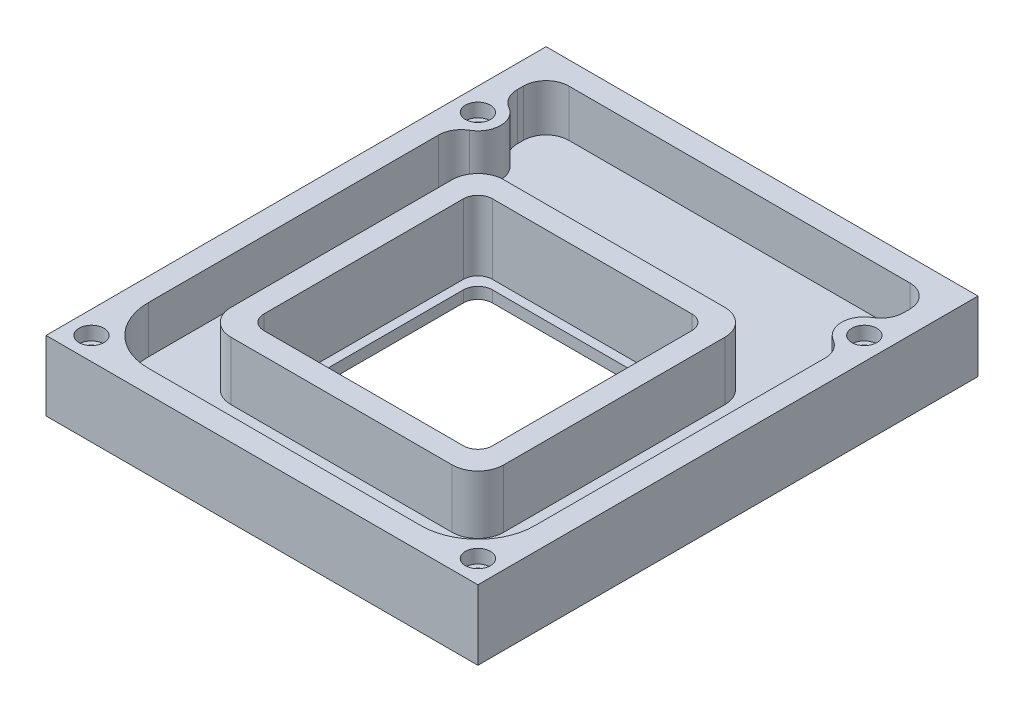
from build123d import *

# Parameters (mm, degrees)
SKETCH1_W           = 190
SKETCH1_H           = 220
SKETCH1_W_2         = 150
SKETCH1_H_2         = 180
SKETCH1_W_3         = 120
SKETCH1_H_3         = 120
SKETCH1_W_4         = 100
SKETCH1_H_4         = 100
BOSS_EXTRUDE1_DEPTH = 10
SKETCH1_3_W         = 190
SKETCH1_3_H         = 220
SKETCH1_3_W_2       = 150
SKETCH1_3_H_2       = 180
SKETCH1_3_W_3       = 120
SKETCH1_3_H_3       = 120
SKETCH1_3_W_4       = 100
SKETCH1_3_H_4       = 100
BOSS_EXTRUDE2_DEPTH = 35.693
SKETCH3_W           = 190
SKETCH3_H           = 220
SKETCH3_W_2         = 150
SKETCH3_H_2         = 180
CUT_EXTRUDE1_DEPTH  = 5
SKETCH5_R           = 5.5565
CUT_EXTRUDE2_DEPTH  = 22
SKETCH7_R           = 3.3
CUT_EXTRUDE3_DEPTH  = 14.693
CUT_EXTRUDE4_START  = -1e-06
SKETCH8_W           = 146
SKETCH8_H           = 180
CUT_EXTRUDE4_DEPTH  = 20.693001
FILLET1_R           = 10
SKETCH10_R          = 5.5
CUT_EXTRUDE5_DEPTH  = 6
BOSS_EXTRUDE5_START = -1e-06
BOSS_EXTRUDE5_DEPTH = 20.693001
CUT_EXTRUDE10_REACH = 37.693
SKETCH13_W          = 100.5
SKETCH13_H          = 100.5
FILLET2_R           = 11.35
SKETCH14_W          = 100.5
SKETCH14_H          = 100.5
SKETCH14_W_2        = 92.5
SKETCH14_H_2        = 92.5
BOSS_EXTRUDE6_DEPTH = 5
FILLET3_R           = 6.35
FILLET4_R           = 6.35


with BuildPart() as part:
    # Sketch1 → Boss-Extrude1 (new body)
    with BuildSketch(Plane(origin=(0, 0, 0), x_dir=(1, 0, 0), z_dir=(0, 1, 0))):
        with Locations((0, 15)):
            Rectangle(SKETCH1_W, SKETCH1_H)
        with Locations((0, 15)):
            Rectangle(SKETCH1_W_2, SKETCH1_H_2, mode=Mode.SUBTRACT)
        with Locations((0, 15)):
            Rectangle(SKETCH1_W_2, SKETCH1_H_2)
        Rectangle(SKETCH1_W_3, SKETCH1_H_3, mode=Mode.SUBTRACT)
        Rectangle(SKETCH1_W_3, SKETCH1_H_3)
        Rectangle(SKETCH1_W_4, SKETCH1_H_4, mode=Mode.SUBTRACT)
    extrude(amount=BOSS_EXTRUDE1_DEPTH)

    # Sketch1_3 → Boss-Extrude2 (add)
    with BuildSketch(Plane(origin=(0, 0, 0), x_dir=(1, 0, 0), z_dir=(0, 1, 0))):
        with Locations((0, 15)):
            Rectangle(SKETCH1_3_W, SKETCH1_3_H)
        with Locations((0, 15)):
            Rectangle(SKETCH1_3_W_2, SKETCH1_3_H_2, mode=Mode.SUBTRACT)
        Rectangle(SKETCH1_3_W_3, SKETCH1_3_H_3)
        Rectangle(SKETCH1_3_W_4, SKETCH1_3_H_4, mode=Mode.SUBTRACT)
    extrude(amount=BOSS_EXTRUDE2_DEPTH)

    # Sketch3 → Cut-Extrude1 (cut)
    with BuildSketch(Plane(origin=(0, 35.693, 0), x_dir=(1, 0, 0), z_dir=(0, 1, 0))):
        with Locations((0, 15)):
            Rectangle(SKETCH3_W, SKETCH3_H)
        with Locations((0, 15)):
            Rectangle(SKETCH3_W_2, SKETCH3_H_2, mode=Mode.SUBTRACT)
    extrude(amount=-CUT_EXTRUDE1_DEPTH, mode=Mode.SUBTRACT)

    # Sketch5 → Cut-Extrude2 (cut)
    with BuildSketch(Plane(origin=(0, 0, 0), x_dir=(-1, 0, 0), z_dir=(0, -1, 0))):
        with Locations((85, 85)):
            Circle(SKETCH5_R)
        with Locations((85, -85)):
            Circle(SKETCH5_R)
        with Locations((-85, -85)):
            Circle(SKETCH5_R)
        with Locations((-85, 85)):
            Circle(SKETCH5_R)
    extrude(amount=-CUT_EXTRUDE2_DEPTH, mode=Mode.SUBTRACT)

    # Sketch7 → Cut-Extrude3 (cut, through all)
    with BuildSketch(Plane(origin=(0, 22, 0), x_dir=(-1, 0, 0), z_dir=(0, -1, 0))):
        with Locations((85, 85)):
            Circle(SKETCH7_R)
        with Locations((85, -85)):
            Circle(SKETCH7_R)
        with Locations((-85, -85)):
            Circle(SKETCH7_R)
        with Locations((-85, 85)):
            Circle(SKETCH7_R)
    extrude(amount=-CUT_EXTRUDE3_DEPTH, mode=Mode.SUBTRACT)

    # Sketch8 → Cut-Extrude4 (cut)
    with BuildSketch(Plane(origin=(0, 10, 0), x_dir=(1, 0, 0), z_dir=(0, 1, 0)).offset(CUT_EXTRUDE4_START)):
        with BuildLine():
            Line((85, 115), (-85, 115))
            Line((-85, 115), (-85, 95))
            ThreePointArc((-85, 95), (-75, 85), (-85, 75))
            Line((-85, 75), (-85, -75))
            ThreePointArc((-85, -75), (-77.928932188, -77.928932188), (-75, -85))
            Line((-75, -85), (75, -85))
            ThreePointArc((75, -85), (77.928932188, -77.928932188), (85, -75))
            Line((85, -75), (85, 75))
            ThreePointArc((85, 75), (75, 85), (85, 95))
            Line((85, 95), (85, 115))
        make_face()
        with Locations((0, 15)):
            Rectangle(SKETCH8_W, SKETCH8_H, mode=Mode.SUBTRACT)
    extrude(amount=CUT_EXTRUDE4_DEPTH, mode=Mode.SUBTRACT)

    # Fillet1
    fillet1_edges = [part.edges().sort_by_distance(p)[0] for p in [
        (85, 20.3464995, -75),
        (-85, 20.3464995, -75),
        (-85, 20.3464995, -95),
        (85, 20.3464995, -95),
        (85, 20.3464995, -115),
        (-85, 20.3464995, -115),
    ]]
    fillet(fillet1_edges, radius=FILLET1_R)

    # Sketch10 → Cut-Extrude5 (cut)
    with BuildSketch(Plane(origin=(0, 30.693, 0), x_dir=(1, 0, 0), z_dir=(0, 1, 0))):
        with Locations((85, 85)):
            Circle(SKETCH10_R)
        with Locations((85, -85)):
            Circle(SKETCH10_R)
        with Locations((-85, -85)):
            Circle(SKETCH10_R)
        with Locations((-85, 85)):
            Circle(SKETCH10_R)
    extrude(amount=-CUT_EXTRUDE5_DEPTH, mode=Mode.SUBTRACT)

    # Sketch11 → Boss-Extrude5 (add)
    with BuildSketch(Plane(origin=(0, 10, 0), x_dir=(1, 0, 0), z_dir=(0, 1, 0)).offset(BOSS_EXTRUDE5_START)):
        with BuildLine():
            ThreePointArc((60, -85), (77.67766953, -77.67766953), (85, -60))
            ThreePointArc((85, -60), (81.110912703, -81.110912703), (60, -85))
        make_face()
        with BuildLine():
            ThreePointArc((-85, -60), (-77.67766953, -77.67766953), (-60, -85))
            ThreePointArc((-60, -85), (-81.110912703, -81.110912703), (-85, -60))
        make_face()
    extrude(amount=BOSS_EXTRUDE5_DEPTH)

    # Sketch13 → Cut-Extrude10 (cut, up to next)
    with BuildSketch(Plane(origin=(0, 0, 0), x_dir=(1, 0, 0), z_dir=(0, 1, 0)), mode=Mode.PRIVATE) as cut_extrude10_sk1:
        Rectangle(SKETCH13_W, SKETCH13_H)
    cut_extrude10_tool1 = extrude(cut_extrude10_sk1.sketch, amount=CUT_EXTRUDE10_REACH, mode=Mode.PRIVATE) & part.part
    add(cut_extrude10_tool1.solids().sort_by_distance((0, 0, 0))[0], mode=Mode.SUBTRACT)

    # Fillet2
    fillet2_edges = [part.edges().sort_by_distance(p)[0] for p in [
        (60, 22.8465, 60),
        (60, 22.8465, -60),
        (-60, 22.8465, -60),
        (-60, 22.8465, 60),
    ]]
    fillet(fillet2_edges, radius=FILLET2_R)

    # Sketch14 → Boss-Extrude6 (add)
    with BuildSketch(Plane(origin=(0, 0, 0), x_dir=(1, 0, 0), z_dir=(0, 1, 0))):
        Rectangle(SKETCH14_W, SKETCH14_H)
        Rectangle(SKETCH14_W_2, SKETCH14_H_2, mode=Mode.SUBTRACT)
    extrude(amount=BOSS_EXTRUDE6_DEPTH)

    # Fillet3
    fillet3_edges = [part.edges().sort_by_distance(p)[0] for p in [
        (-50.25, 20.3465, -50.25),
        (-50.25, 20.3465, 50.25),
        (50.25, 20.3465, 50.25),
        (50.25, 20.3465, -50.25),
    ]]
    fillet(fillet3_edges, radius=FILLET3_R)

    # Fillet4
    fillet4_edges = [part.edges().sort_by_distance(p)[0] for p in [
        (46.25, 2.5, -46.25),
        (-46.25, 2.5, -46.25),
        (-46.25, 2.5, 46.25),
        (46.25, 2.5, 46.25),
    ]]
    fillet(fillet4_edges, radius=FILLET4_R)


solid = part.part
